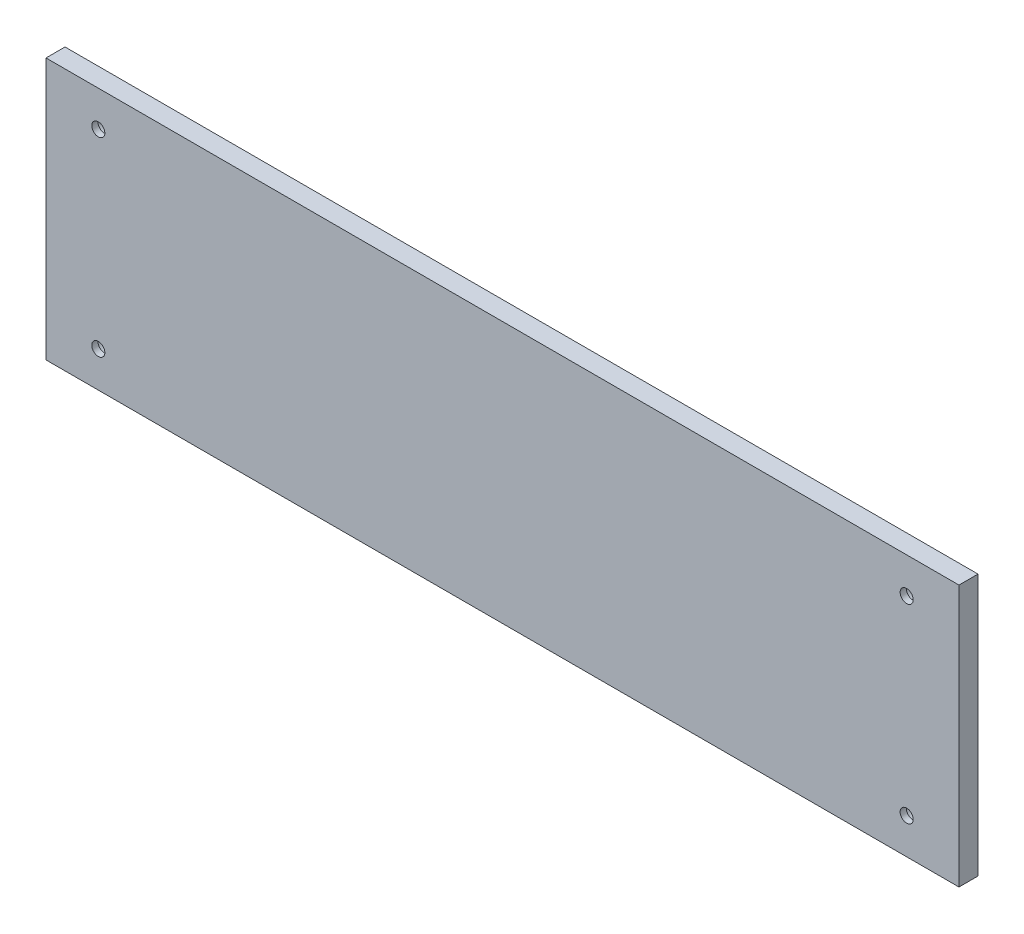
from build123d import *

# Parameters (mm, degrees)
SKETCH1_W                                           = 384
SKETCH1_H                                           = 110
EXTRUDE2_DEPTH                                      = 8
CBORE_FOR_M5_HEX_SOCKET_HEAD_CAP_SCREW1_D           = 5.5
CBORE_FOR_M5_HEX_SOCKET_HEAD_CAP_SCREW1_CBORE_D     = 10
CBORE_FOR_M5_HEX_SOCKET_HEAD_CAP_SCREW1_CBORE_DEPTH = 5.4


with BuildPart() as part:
    # Sketch1 → Extrude2 (new body)
    with BuildSketch(Plane.XY):
        with Locations((192, 55)):
            Rectangle(SKETCH1_W, SKETCH1_H)
    extrude(amount=EXTRUDE2_DEPTH)

    # CBORE for M5 Hex Socket Head Cap Screw1 (through all)
    with Locations(Plane(origin=(362, 95, 0), x_dir=(-1, 0, 0), z_dir=(0, 0, -1))):
        with Locations((0, 0), (340, 0), (340, -80), (0, -80)):
            CounterBoreHole(CBORE_FOR_M5_HEX_SOCKET_HEAD_CAP_SCREW1_D / 2, CBORE_FOR_M5_HEX_SOCKET_HEAD_CAP_SCREW1_CBORE_D / 2, CBORE_FOR_M5_HEX_SOCKET_HEAD_CAP_SCREW1_CBORE_DEPTH)


solid = part.part
